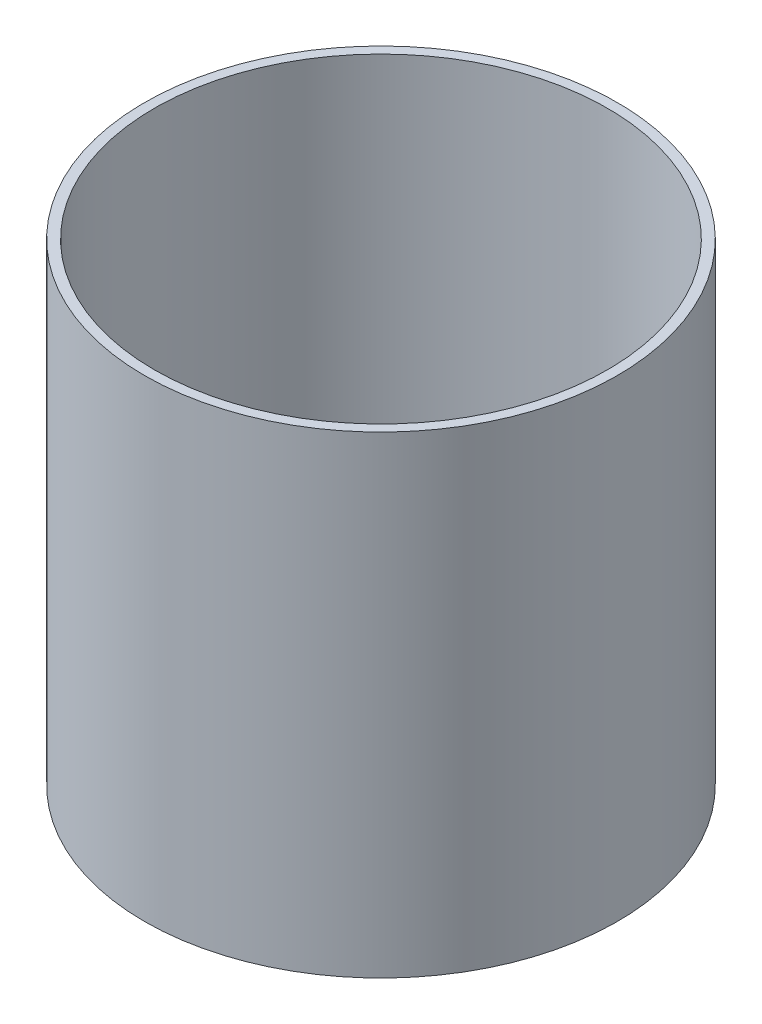
from build123d import *

# Parameters (mm, degrees)
SKETCH1_R           = 152.4
SKETCH1_R_2         = 146.05
BOSS_EXTRUDE1_DEPTH = 304.8


with BuildPart() as part:
    # Sketch1 → Boss-Extrude1 (new body)
    with BuildSketch(Plane(origin=(0, 0, 0), x_dir=(1, 0, 0), z_dir=(0, 1, 0))):
        Circle(SKETCH1_R)
        Circle(SKETCH1_R_2, mode=Mode.SUBTRACT)
    extrude(amount=BOSS_EXTRUDE1_DEPTH)


solid = part.part
